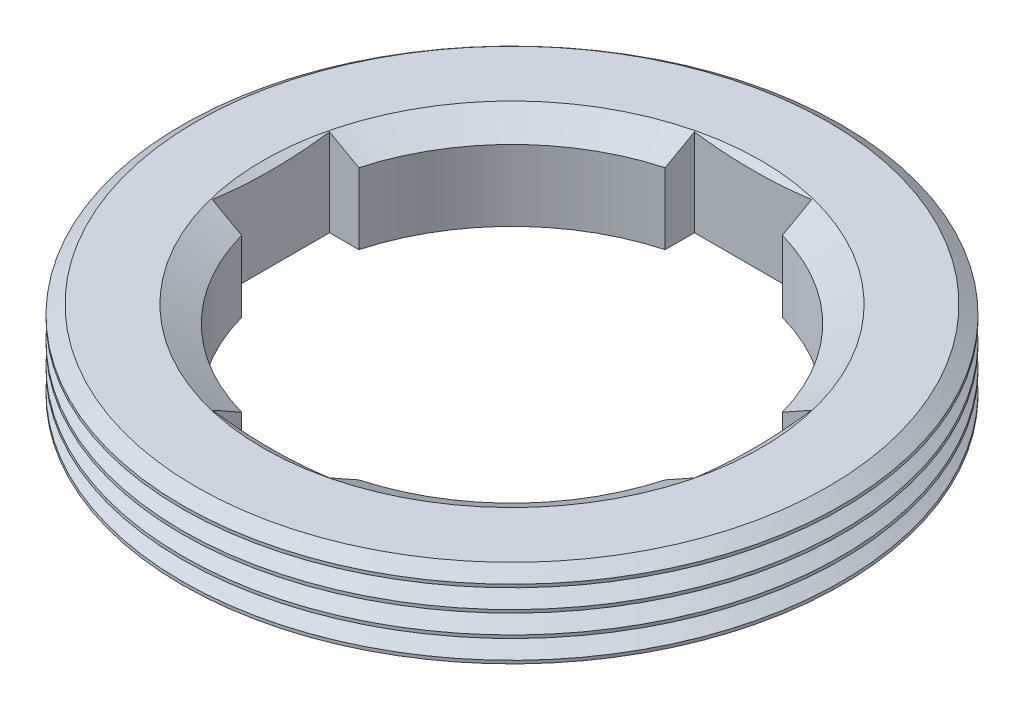
from build123d import *

# Parameters (mm, degrees)
SKETCH_1_R                    = 22.5
SKETCH_1_R_2                  = 15
EXTRUDE_1_DEPTH               = 6
PATTERN_LINEAR_45_1_5_1_COUNT = 5
PATTERN_LINEAR_45_1_5_1_PITCH = 1.5
SKETCH_4_W                    = 2
SKETCH_4_H                    = 8
CUT_EXTRUDE_2_DEPTH           = 7
PATTERN_CIRCULAR_1_COUNT      = 4


with BuildPart() as part:
    # Эскиз1 → Вытянуть1 (new body)
    with BuildSketch(Plane(origin=(0, 0, 0), x_dir=(1, 0, 0), z_dir=(0, 1, 0))):
        Circle(SKETCH_1_R)
        Circle(SKETCH_1_R_2, mode=Mode.SUBTRACT)
    extrude(amount=EXTRUDE_1_DEPTH)

    # Эскиз2 → М45х1,5 1й зуб (revolve, cut)
    with BuildSketch(Plane(origin=(0, 0, 0), x_dir=(0, 0, -1), z_dir=(1, 0, 0))):
        Polygon((-21.58, 6), (-22.5, 5.355809065), (-25, 5.355809065), (-25, 6.644190935), (-22.5, 6.644190935), align=None)
    cut_revolve_45_1_5_1 = revolve(axis=Axis((0, 0, 0), (0, 1, 0)), mode=Mode.SUBTRACT)

    # Эскиз3 → Вырез-Повернуть2 (revolve, cut)
    with BuildSketch(Plane(origin=(0, 0, 0), x_dir=(0, 0, -1), z_dir=(1, 0, 0))):
        Polygon((-15, 4.845299462), (-17, 6), (-15, 6), align=None)
    revolve(axis=Axis((0, 0, 0), (0, 1, 0)), mode=Mode.SUBTRACT)

    # М45х1,5 массив1: М45х1,5 1й зуб ×5
    with Locations(*[(0, -i * PATTERN_LINEAR_45_1_5_1_PITCH, 0) for i in range(1, PATTERN_LINEAR_45_1_5_1_COUNT)]):
        add(cut_revolve_45_1_5_1, mode=Mode.SUBTRACT)

    # Эскиз4 → Вытянуть2 (cut, through all)
    with BuildSketch(Plane(origin=(0, 6, 0), x_dir=(1, 0, 0), z_dir=(0, 1, 0))):
        with Locations((15.456832295, 0)):
            Rectangle(SKETCH_4_W, SKETCH_4_H)
    cut_extrude_2 = extrude(amount=-CUT_EXTRUDE_2_DEPTH, mode=Mode.SUBTRACT)

    # Круговой массив1: Вытянуть2 ×4 about axis
    pattern_circular_1_axis = Axis((0, 0, 0), (0, 1, 0))
    for i in range(1, PATTERN_CIRCULAR_1_COUNT):
        add(cut_extrude_2.rotate(pattern_circular_1_axis, i * 360 / PATTERN_CIRCULAR_1_COUNT), mode=Mode.SUBTRACT)


solid = part.part
